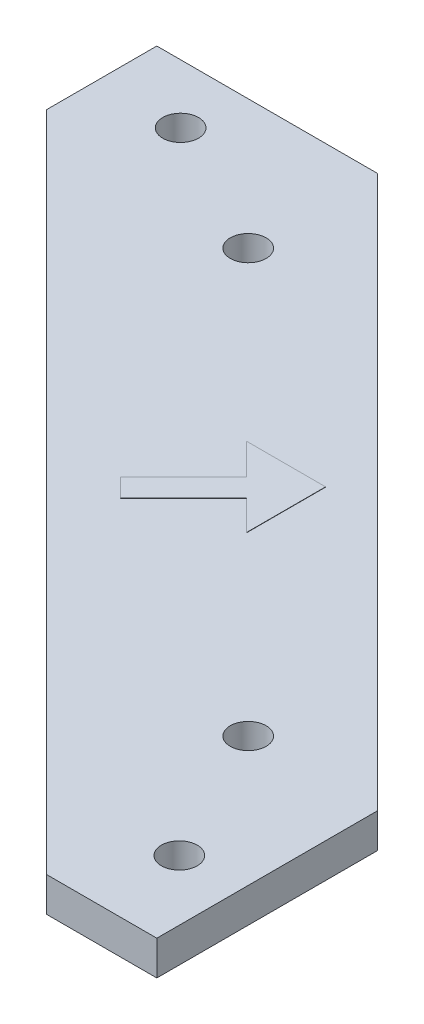
from build123d import *

# Parameters (mm, degrees)
SKETCH1_R           = 1.651
BOSS_EXTRUDE2_DEPTH = 3.175
BOSS_EXTRUDE3_DEPTH = 0.0254


with BuildPart() as part:
    # Sketch1 → Boss-Extrude2 (new body)
    with BuildSketch(Plane(origin=(0, 0, 0), x_dir=(1, 0, 0), z_dir=(0, 1, 0))):
        Polygon((0, -50.8), (-50.8, 0), (-71.12, 0), (-71.12, -10.16), (-10.16, -71.12), (0, -71.12), align=None)
        with Locations((-5.55625, -63.492108138)):
            Circle(SKETCH1_R, mode=Mode.SUBTRACT)
        with Locations((-11.90625, -50.8)):
            Circle(SKETCH1_R, mode=Mode.SUBTRACT)
        with Locations((-63.5, -5.42925)):
            Circle(SKETCH1_R, mode=Mode.SUBTRACT)
        with Locations((-50.8, -11.90625)):
            Circle(SKETCH1_R, mode=Mode.SUBTRACT)
    extrude(amount=BOSS_EXTRUDE2_DEPTH)

    # Sketch5 → Boss-Extrude3 (add)
    with BuildSketch(Plane(origin=(0, 3.175, 0), x_dir=(1, 0, 0), z_dir=(0, 1, 0))):
        Polygon((-28.185982934, -27.400888033), (-35.474882305, -27.400888033), (-32.595449328, -30.28032101), (-38.384718685, -36.069590367), (-36.729980154, -37.724328898), (-30.940710797, -31.935059541), (-28.185982934, -34.689787404), align=None)
    extrude(amount=BOSS_EXTRUDE3_DEPTH)


solid = part.part
